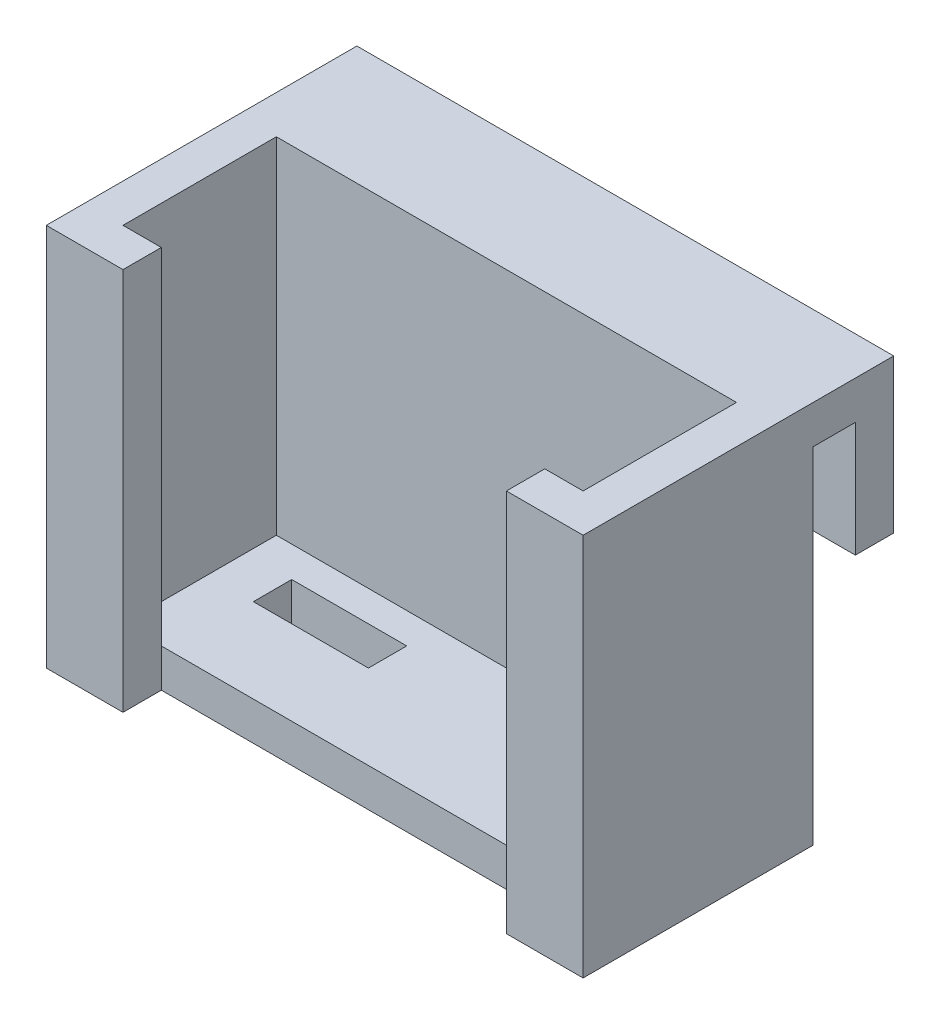
from build123d import *

# Parameters (mm, degrees)
SKETCH1_W           = 60
SKETCH1_H           = 20
BOSS_EXTRUDE1_DEPTH = 5
SKETCH2_W           = 15
SKETCH2_H           = 5
CUT_EXTRUDE1_DEPTH  = 5
SKETCH3_W           = 60
SKETCH3_H           = 50
BOSS_EXTRUDE2_DEPTH = 5
SKETCH4_W           = 25
SKETCH4_H           = 50
BOSS_EXTRUDE3_DEPTH = 5
SKETCH5_W           = 25
SKETCH5_H           = 50
BOSS_EXTRUDE4_DEPTH = 5
SKETCH7_W           = 10
SKETCH7_H           = 50
BOSS_EXTRUDE5_DEPTH = 5
SKETCH8_W           = 10
SKETCH8_H           = 50
BOSS_EXTRUDE6_DEPTH = 5
SKETCH9_W           = 70
SKETCH9_H           = 5.5
BOSS_EXTRUDE8_DEPTH = 5
SKETCH11_W          = 70
SKETCH11_H          = 20
BOSS_EXTRUDE9_DEPTH = 5


with BuildPart() as part:
    # Sketch1 → Boss-Extrude1 (new body)
    with BuildSketch(Plane(origin=(0, 0, 0), x_dir=(1, 0, 0), z_dir=(0, 1, 0))):
        Rectangle(SKETCH1_W, SKETCH1_H)
    extrude(amount=BOSS_EXTRUDE1_DEPTH)

    # Sketch2 → Cut-Extrude1 (cut)
    with BuildSketch(Plane(origin=(0, 5, 0), x_dir=(1, 0, 0), z_dir=(0, 1, 0))):
        with Locations((-16.5, 3.5)):
            Rectangle(SKETCH2_W, SKETCH2_H)
    extrude(amount=-CUT_EXTRUDE1_DEPTH, mode=Mode.SUBTRACT)

    # Sketch3 → Boss-Extrude2 (add)
    with BuildSketch(Plane(origin=(0, 0, -10), x_dir=(-1, 0, 0), z_dir=(0, 0, -1))):
        with Locations((0, 25)):
            Rectangle(SKETCH3_W, SKETCH3_H)
    extrude(amount=BOSS_EXTRUDE2_DEPTH)

    # Sketch4 → Boss-Extrude3 (add)
    with BuildSketch(Plane(origin=(30, 0, 0), x_dir=(0, 0, -1), z_dir=(1, 0, 0))):
        with Locations((2.5, 25)):
            Rectangle(SKETCH4_W, SKETCH4_H)
    extrude(amount=BOSS_EXTRUDE3_DEPTH)

    # Sketch5 → Boss-Extrude4 (add)
    with BuildSketch(Plane.ZY.offset(30)):
        with Locations((-2.5, 25)):
            Rectangle(SKETCH5_W, SKETCH5_H)
    extrude(amount=BOSS_EXTRUDE4_DEPTH)

    # Sketch7 → Boss-Extrude5 (add)
    with BuildSketch(Plane.XY.offset(10)):
        with Locations((30, 25)):
            Rectangle(SKETCH7_W, SKETCH7_H)
    extrude(amount=BOSS_EXTRUDE5_DEPTH)

    # Sketch8 → Boss-Extrude6 (add)
    with BuildSketch(Plane.XY.offset(10)):
        with Locations((-30, 25)):
            Rectangle(SKETCH8_W, SKETCH8_H)
    extrude(amount=BOSS_EXTRUDE6_DEPTH)

    # Sketch9 → Boss-Extrude8 (add)
    with BuildSketch(Plane(origin=(0, 50, 0), x_dir=(1, 0, 0), z_dir=(0, 1, 0))):
        with Locations((0, 17.75)):
            Rectangle(SKETCH9_W, SKETCH9_H)
    extrude(amount=-BOSS_EXTRUDE8_DEPTH)

    # Sketch11 → Boss-Extrude9 (add)
    with BuildSketch(Plane(origin=(0, 0, -20.5), x_dir=(-1, 0, 0), z_dir=(0, 0, -1))):
        with Locations((0, 40)):
            Rectangle(SKETCH11_W, SKETCH11_H)
    extrude(amount=BOSS_EXTRUDE9_DEPTH)


solid = part.part
